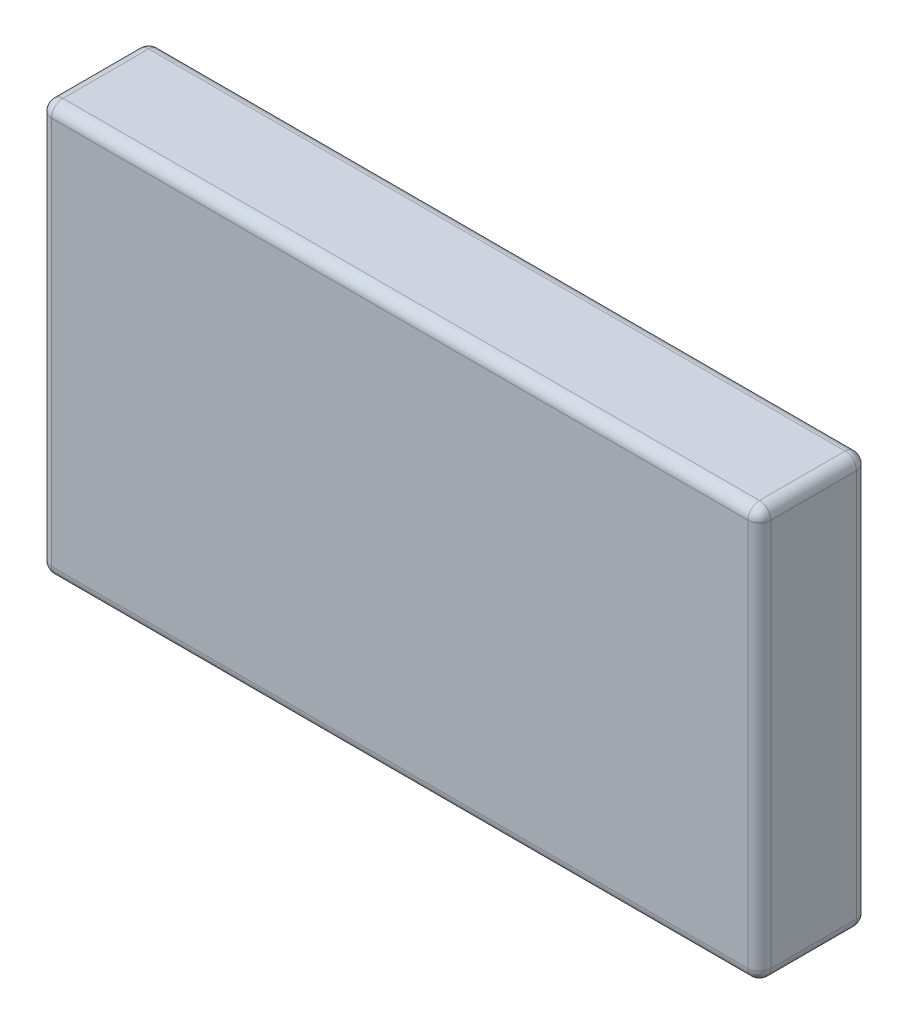
from build123d import *

# Parameters (mm, degrees)
SKETCH_1_W      = 126
SKETCH_1_H      = 72
EXTRUDE_1_DEPTH = 19
FILLET_1_R      = 2


with BuildPart() as part:
    # 草图1 → 凸台-拉伸1 (new body)
    with BuildSketch(Plane.XY):
        Rectangle(SKETCH_1_W, SKETCH_1_H)
    extrude(amount=EXTRUDE_1_DEPTH)

    # 圆角1
    fillet_1_edges = [part.edges().sort_by_distance(p)[0] for p in [
        (63, 0, 19),
        (0, 36, 19),
        (-63, 0, 19),
        (0, 36, 0),
        (63, 0, 0),
        (0, -36, 0),
        (-63, 0, 0),
        (-63, 36, 9.5),
        (63, 36, 9.5),
        (63, -36, 9.5),
        (-63, -36, 9.5),
        (0, -36, 19),
    ]]
    fillet(fillet_1_edges, radius=FILLET_1_R)


solid = part.part
